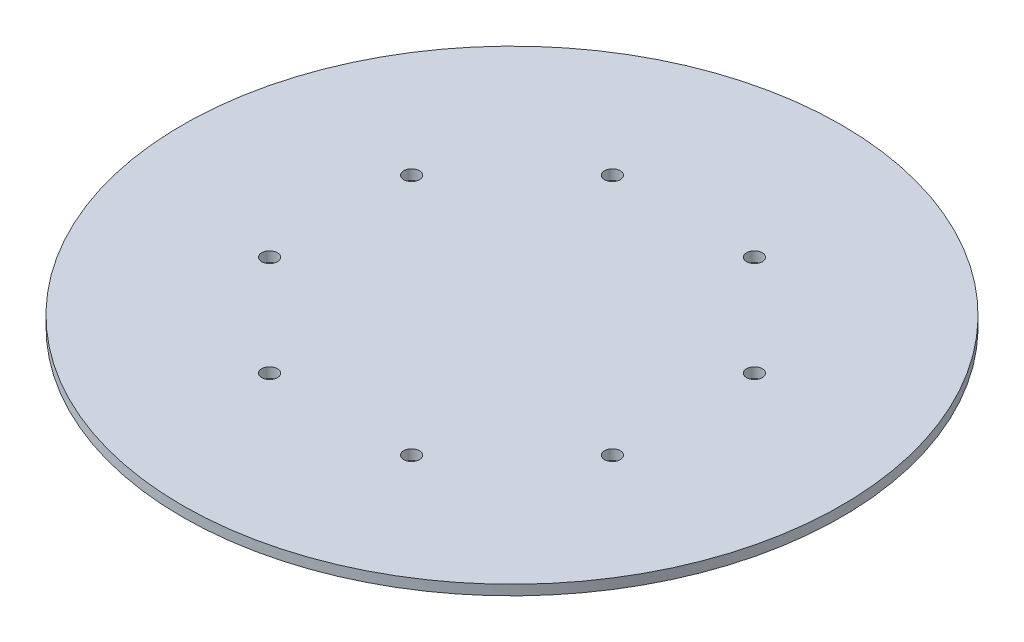
from build123d import *

# Parameters (mm, degrees)
SKETCH1_R           = 52.5
SKETCH1_R_2         = 1.25
BOSS_EXTRUDE1_DEPTH = 1.6


with BuildPart() as part:
    # Sketch1 → Boss-Extrude1 (new body)
    with BuildSketch(Plane(origin=(0, 0, 0), x_dir=(1, 0, 0), z_dir=(0, 1, 0))):
        Circle(SKETCH1_R)
        with Locations((11.312473916, -27.310727951)):
            Circle(SKETCH1_R_2, mode=Mode.SUBTRACT)
        with Locations((-11.312473916, -27.310727951)):
            Circle(SKETCH1_R_2, mode=Mode.SUBTRACT)
        with Locations((-27.310727951, -11.312473916)):
            Circle(SKETCH1_R_2, mode=Mode.SUBTRACT)
        with Locations((-27.310727951, 11.312473916)):
            Circle(SKETCH1_R_2, mode=Mode.SUBTRACT)
        with Locations((-11.312473916, 27.310727951)):
            Circle(SKETCH1_R_2, mode=Mode.SUBTRACT)
        with Locations((11.312473916, 27.310727951)):
            Circle(SKETCH1_R_2, mode=Mode.SUBTRACT)
        with Locations((27.310727951, 11.312473916)):
            Circle(SKETCH1_R_2, mode=Mode.SUBTRACT)
        with Locations((27.310727951, -11.312473916)):
            Circle(SKETCH1_R_2, mode=Mode.SUBTRACT)
    extrude(amount=BOSS_EXTRUDE1_DEPTH)


solid = part.part
